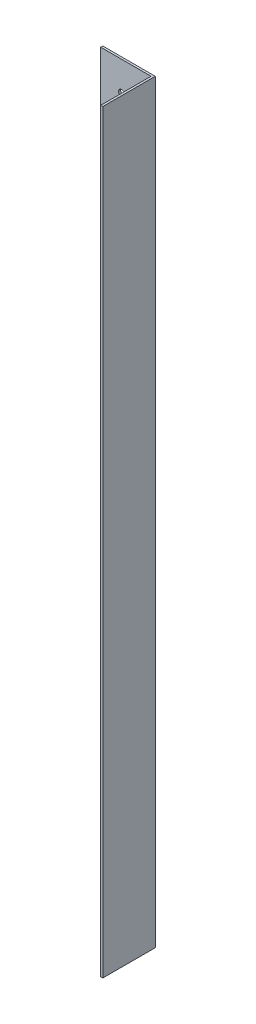
from build123d import *

# Parameters (mm, degrees)
CROQUIS1_W              = 24
CROQUIS1_H              = 360
CROQUIS1_R              = 1.5
SALIENTE_EXTRUIR1_DEPTH = 1
CROQUIS2_W              = 1
CROQUIS2_H              = 360
SALIENTE_EXTRUIR2_DEPTH = 25


with BuildPart() as part:
    # Croquis1 → Saliente-Extruir1 (new body)
    with BuildSketch(Plane.XY):
        with Locations((-41.401725042, -153.514805415)):
            Rectangle(CROQUIS1_W, CROQUIS1_H)
        with Locations((-43.401725042, 12.485194585)):
            Circle(CROQUIS1_R, mode=Mode.SUBTRACT)
        with Locations((-43.401725042, -319.514805415)):
            Circle(CROQUIS1_R, mode=Mode.SUBTRACT)
    extrude(amount=SALIENTE_EXTRUIR1_DEPTH)

    # Croquis2 → Saliente-Extruir2 (add)
    with BuildSketch(Plane.XY):
        with Locations((-28.901725042, -153.514805415)):
            Rectangle(CROQUIS2_W, CROQUIS2_H)
    extrude(amount=SALIENTE_EXTRUIR2_DEPTH)


solid = part.part
